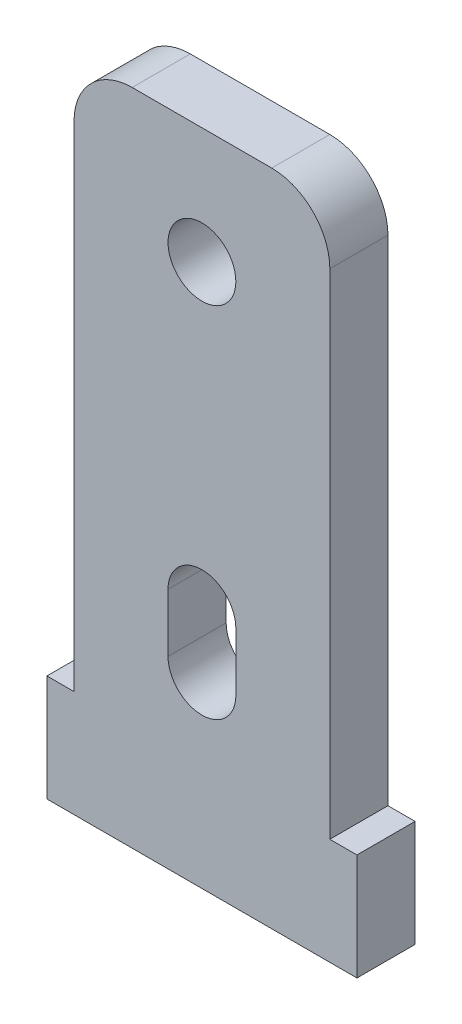
from build123d import *

# Parameters (mm, degrees)
SKETCH1_R           = 1.75
SKETCH1_W           = 16
SKETCH1_H           = 5.5
BOSS_EXTRUDE1_DEPTH = 3


with BuildPart() as part:
    # Sketch1 → Boss-Extrude1 (new body)
    with BuildSketch(Plane.XY):
        with BuildLine():
            Line((-3.6, 18.5), (3.6, 18.5))
            ThreePointArc((3.6, 18.5), (5.721320344, 17.621320344), (6.6, 15.5))
            Line((6.6, 15.5), (6.6, -15.5))
            Line((6.6, -15.5), (-6.6, -15.5))
            Line((-6.6, -15.5), (-6.6, 15.5))
            ThreePointArc((-6.6, 15.5), (-5.721320344, 17.621320344), (-3.6, 18.5))
        make_face()
        with Locations((0, 12.5)):
            Circle(SKETCH1_R, mode=Mode.SUBTRACT)
        with BuildLine():
            Line((1.75, -3), (1.75, -6))
            ThreePointArc((1.75, -6), (0, -7.75), (-1.75, -6))
            Line((-1.75, -6), (-1.75, -3))
            ThreePointArc((-1.75, -3), (0, -1.25), (1.75, -3))
        make_face(mode=Mode.SUBTRACT)
        with Locations((0, -12.75)):
            Rectangle(SKETCH1_W, SKETCH1_H)
    extrude(amount=BOSS_EXTRUDE1_DEPTH)


solid = part.part
